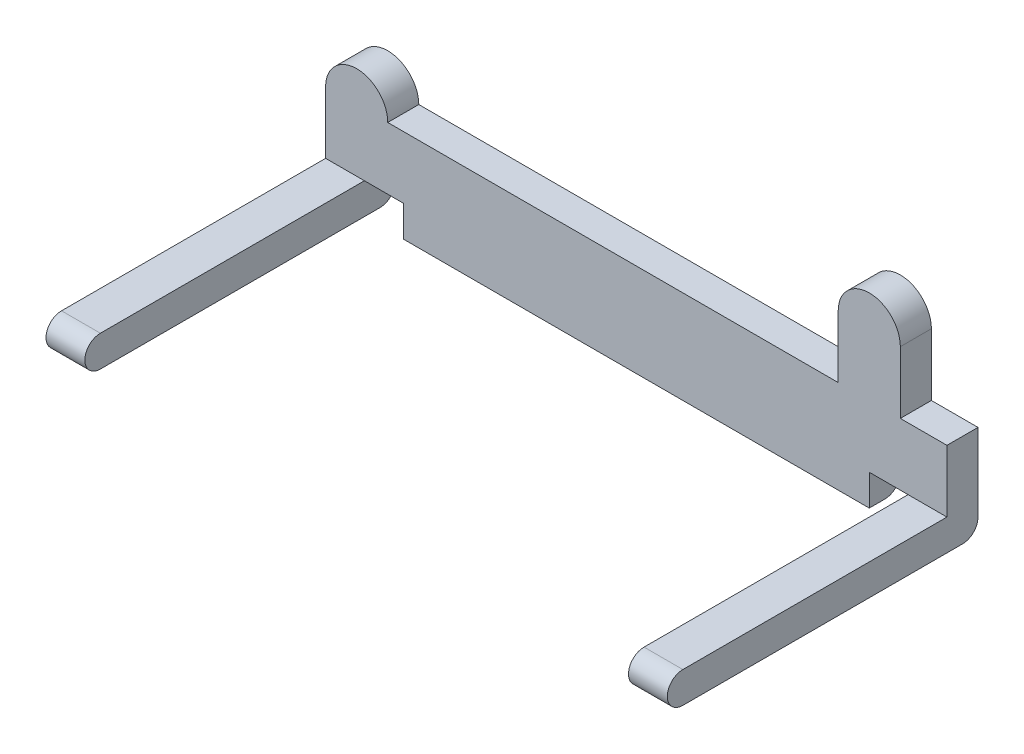
from build123d import *

# Parameters (mm, degrees)
EXTRUDE_1_DEPTH     = 80
SKETCH_10_W         = 4
SKETCH_10_H         = 8
EXTRUDE_8_DEPTH     = 80
SKETCH_11_R         = 4
EXTRUDE_9_DEPTH     = 4
SKETCH_12_W         = 70
SKETCH_12_H         = 40.815900945
CUT_EXTRUDE_1_DEPTH = 10
SKETCH_13_W         = 5
SKETCH_13_H         = 4
CUT_EXTRUDE_2_DEPTH = 10


with BuildPart() as part:
    # 草图1 → 凸台-拉伸1 (new body)
    with BuildSketch(Plane(origin=(0, 0, 0), x_dir=(0, 0, -1), z_dir=(1, 0, 0))):
        with BuildLine():
            Line((-18, 2), (18, 2))
            Line((18, 2), (20, 2))
            Line((20, 2), (20, 0))
            ThreePointArc((20, 0), (19.414213562, -1.414213562), (18, -2))
            Line((18, -2), (-18, -2))
            ThreePointArc((-18, -2), (-20, 0), (-18, 2))
        make_face()
    extrude(amount=EXTRUDE_1_DEPTH)

    # 草图10 → 凸台-拉伸8 (add)
    with BuildSketch(Plane(origin=(80, 0, 0), x_dir=(0, 0, -1), z_dir=(1, 0, 0))):
        with Locations((18, 6)):
            Rectangle(SKETCH_10_W, SKETCH_10_H)
    extrude(amount=-EXTRUDE_8_DEPTH)

    # 草图11 → 凸台-拉伸9 (add)
    with BuildSketch(Plane(origin=(0, 0, -20), x_dir=(-1, 0, 0), z_dir=(0, 0, -1))):
        with Locations((-4, 10)):
            Circle(SKETCH_11_R)
        with BuildLine():
            Line((-74, 10), (-66, 10))
            Line((-66, 10), (-66, 18))
            ThreePointArc((-66, 18), (-70, 22), (-74, 18))
            Line((-74, 18), (-74, 10))
        make_face()
    extrude(amount=-EXTRUDE_9_DEPTH)

    # 草图12 → 切除-拉伸1 (cut)
    with BuildSketch(Plane(origin=(0, 2, 0), x_dir=(1, 0, 0), z_dir=(0, 1, 0))):
        with Locations((40, -4.407950473)):
            Rectangle(SKETCH_12_W, SKETCH_12_H)
    extrude(amount=-CUT_EXTRUDE_1_DEPTH, mode=Mode.SUBTRACT)

    # 草图13 → 切除-拉伸2 (cut)
    with BuildSketch(Plane.XY.offset(-16)):
        with Locations((7.5, 0)):
            Rectangle(SKETCH_13_W, SKETCH_13_H)
        with Locations((72.5, 0)):
            Rectangle(SKETCH_13_W, SKETCH_13_H)
    extrude(amount=-CUT_EXTRUDE_2_DEPTH, mode=Mode.SUBTRACT)


solid = part.part
